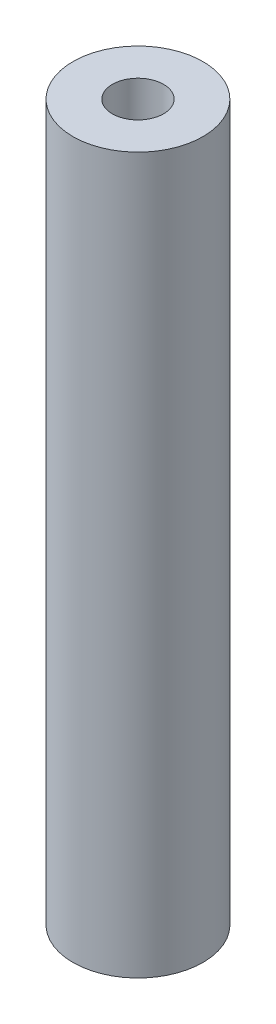
from build123d import *

# Parameters (mm, degrees)
SKETCH1_R                 = 3.175
BOSS_EXTRUDE1_DEPTH       = 34.925
M3X0_5_TAPPED_HOLE1_D     = 2.5
M3X0_5_TAPPED_HOLE1_DEPTH = 12.7
M3X0_5_TAPPED_HOLE1_TIP   = 0.751075774
M3X0_5_TAPPED_HOLE2_D     = 2.5
M3X0_5_TAPPED_HOLE2_DEPTH = 12.7
M3X0_5_TAPPED_HOLE2_TIP   = 0.751075774


with BuildPart() as part:
    # Sketch1 → Boss-Extrude1 (new body)
    with BuildSketch(Plane(origin=(0, 0, 0), x_dir=(1, 0, 0), z_dir=(0, 1, 0))):
        Circle(SKETCH1_R)
    extrude(amount=BOSS_EXTRUDE1_DEPTH)

    # M3x0.5 Tapped Hole1
    with Locations(Plane(origin=(0, 34.925, 0), x_dir=(1, 0, 0), z_dir=(0, 1, 0))):
        with Locations((0, 0)):
            Hole(M3X0_5_TAPPED_HOLE1_D / 2, depth=M3X0_5_TAPPED_HOLE1_DEPTH)
            with Locations((0, 0, -(M3X0_5_TAPPED_HOLE1_DEPTH + M3X0_5_TAPPED_HOLE1_TIP / 2))):  # 118° drill point
                Cone(0, M3X0_5_TAPPED_HOLE1_D / 2, M3X0_5_TAPPED_HOLE1_TIP, mode=Mode.SUBTRACT)

    # M3x0.5 Tapped Hole2
    with Locations(Plane(origin=(0, 0, 0), x_dir=(-1, 0, 0), z_dir=(0, -1, 0))):
        with Locations((0, 0)):
            Hole(M3X0_5_TAPPED_HOLE2_D / 2, depth=M3X0_5_TAPPED_HOLE2_DEPTH)
            with Locations((0, 0, -(M3X0_5_TAPPED_HOLE2_DEPTH + M3X0_5_TAPPED_HOLE2_TIP / 2))):  # 118° drill point
                Cone(0, M3X0_5_TAPPED_HOLE2_D / 2, M3X0_5_TAPPED_HOLE2_TIP, mode=Mode.SUBTRACT)


solid = part.part
